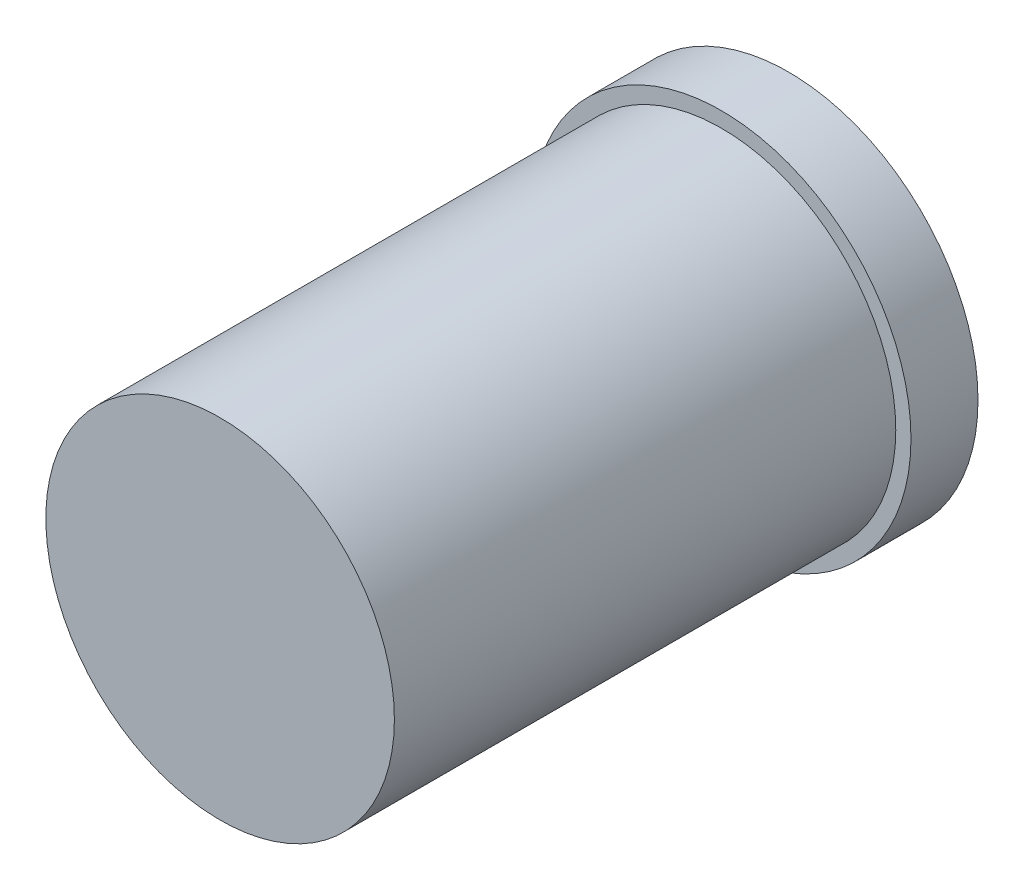
from build123d import *

# Parameters (mm, degrees)
SKETCH1_R           = 2.4765
BOSS_EXTRUDE1_DEPTH = 7.1247
SKETCH2_R           = 2.6924
BOSS_EXTRUDE2_DEPTH = 0.9525


with BuildPart() as part:
    # Sketch1 → Boss-Extrude1 (new body)
    with BuildSketch(Plane.XY):
        Circle(SKETCH1_R)
    extrude(amount=BOSS_EXTRUDE1_DEPTH)

    # Sketch2 → Boss-Extrude2 (add)
    with BuildSketch(Plane(origin=(0, 0, 0), x_dir=(-1, 0, 0), z_dir=(0, 0, -1))):
        Circle(SKETCH2_R)
    extrude(amount=BOSS_EXTRUDE2_DEPTH)


solid = part.part
